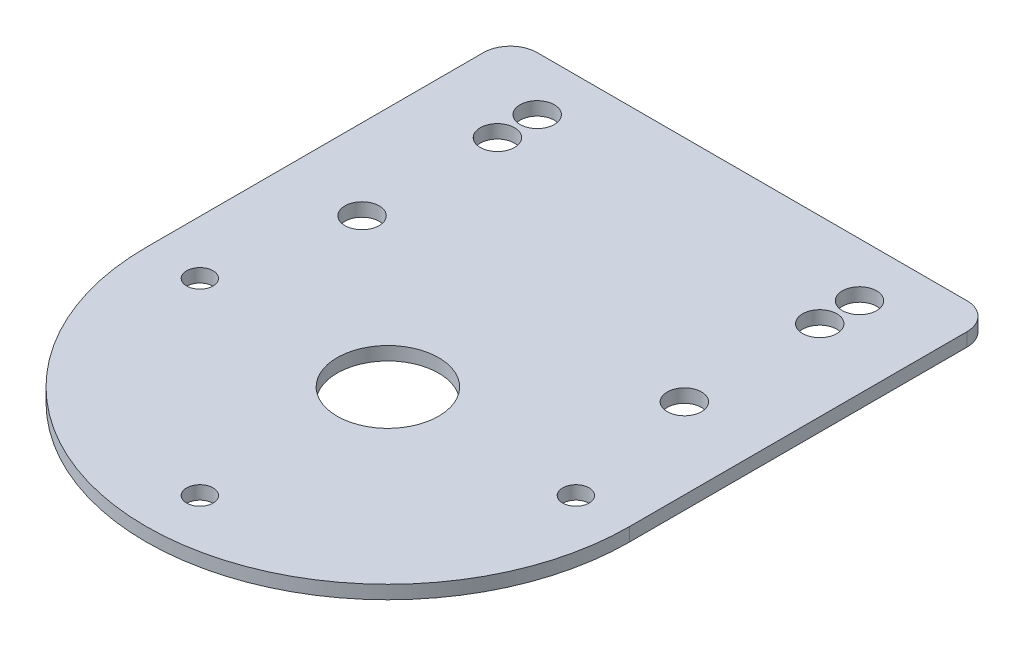
from build123d import *

# Parameters (mm, degrees)
SKETCH1_R           = 6
SKETCH1_R_2         = 1.5625
SKETCH1_R_3         = 2.025
BOSS_EXTRUDE1_DEPTH = 1.5875


with BuildPart() as part:
    # Sketch1 → Boss-Extrude1 (new body)
    with BuildSketch(Plane(origin=(0, 0, 0), x_dir=(1, 0, 0), z_dir=(0, 1, 0))):
        with BuildLine():
            Line((-28.575, 0), (-28.575, 39.875))
            ThreePointArc((-28.575, 39.875), (-27.64506403, 42.12006403), (-25.4, 43.05))
            Line((-25.4, 43.05), (25.4, 43.05))
            ThreePointArc((25.4, 43.05), (27.64506403, 42.12006403), (28.575, 39.875))
            Line((28.575, 39.875), (28.575, 0))
            ThreePointArc((28.575, 0), (0, -28.575), (-28.575, 0))
        make_face()
        Circle(SKETCH1_R, mode=Mode.SUBTRACT)
        with Locations((-22.225, 0)):
            Circle(SKETCH1_R_2, mode=Mode.SUBTRACT)
        with Locations((0, -22.225)):
            Circle(SKETCH1_R_2, mode=Mode.SUBTRACT)
        with Locations((22.225, 0)):
            Circle(SKETCH1_R_2, mode=Mode.SUBTRACT)
        with Locations((-19.05, 16)):
            Circle(SKETCH1_R_3, mode=Mode.SUBTRACT)
        with Locations((19.05, 16)):
            Circle(SKETCH1_R_3, mode=Mode.SUBTRACT)
        with Locations((19.05, 32)):
            Circle(SKETCH1_R_3, mode=Mode.SUBTRACT)
        with Locations((-19.05, 32)):
            Circle(SKETCH1_R_3, mode=Mode.SUBTRACT)
        with Locations((-19.05, 36.7)):
            Circle(SKETCH1_R_3, mode=Mode.SUBTRACT)
        with Locations((19.05, 36.7)):
            Circle(SKETCH1_R_3, mode=Mode.SUBTRACT)
    extrude(amount=BOSS_EXTRUDE1_DEPTH)


solid = part.part
